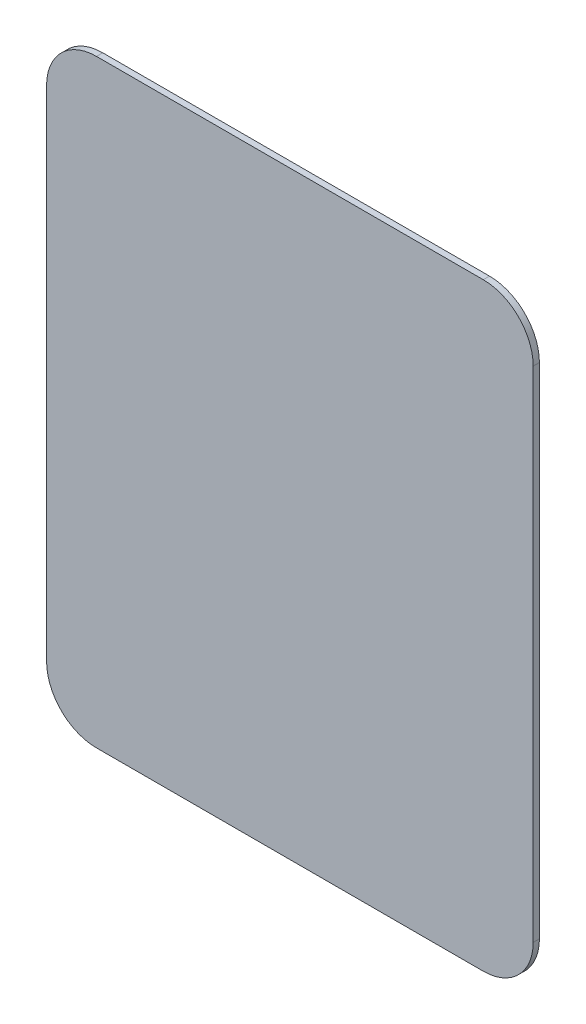
from build123d import *

# Parameters (mm, degrees)
BOSS_EXTRUDE1_DEPTH = 3.175


with BuildPart() as part:
    # Sketch2 → Boss-Extrude1 (new body)
    with BuildSketch(Plane.XY):
        with BuildLine():
            Line((-98.425, -152.4), (98.425, -152.4))
            ThreePointArc((98.425, -152.4), (116.385512242, -144.960512242), (123.825, -127))
            Line((123.825, -127), (123.825, 127))
            ThreePointArc((123.825, 127), (116.385512242, 144.960512242), (98.425, 152.4))
            Line((98.425, 152.4), (-98.425, 152.4))
            ThreePointArc((-98.425, 152.4), (-116.385512242, 144.960512242), (-123.825, 127))
            Line((-123.825, 127), (-123.825, -127))
            ThreePointArc((-123.825, -127), (-116.385512242, -144.960512242), (-98.425, -152.4))
        make_face()
    extrude(amount=BOSS_EXTRUDE1_DEPTH)


solid = part.part
